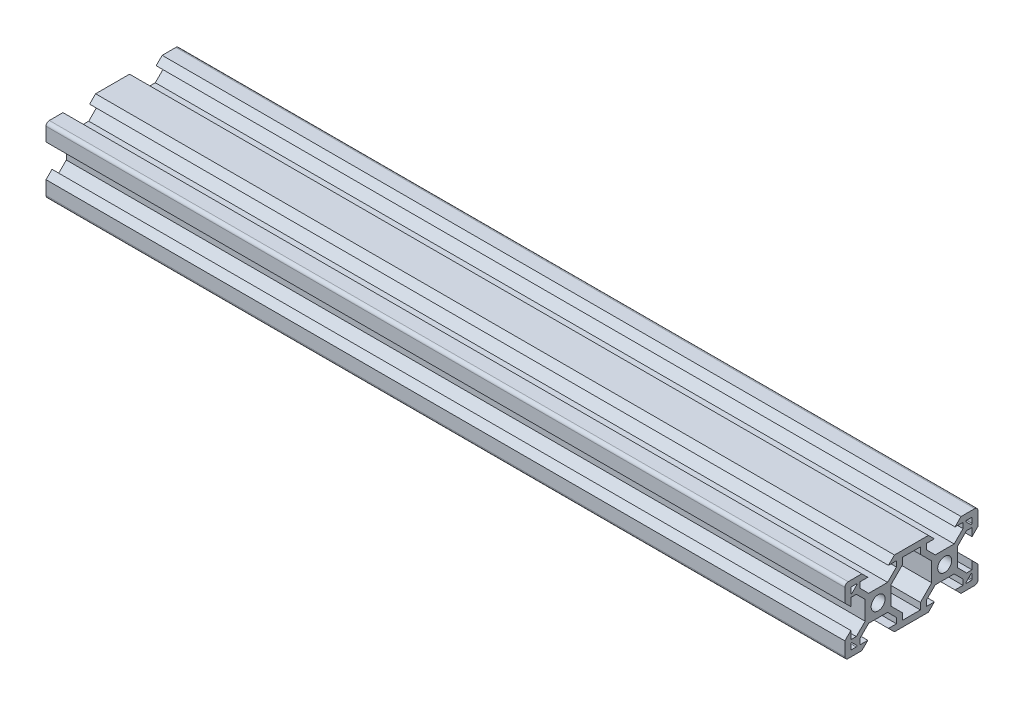
from build123d import *

# Parameters (mm, degrees)
SKETCH5_R           = 2.1
BOSS_EXTRUDE1_DEPTH = 120


with BuildPart() as part:
    # Sketch5 → Boss-Extrude1 (new body, symmetric)
    with BuildSketch(Plane(origin=(0, 0, 0), x_dir=(0, 0, -1), z_dir=(1, 0, 0))):
        with BuildLine():
            Line((-19.998019485, 4.9), (-18.198019485, 3.1))
            Line((-18.198019485, 3.1), (-18.198019485, 5.499339828))
            Line((-18.198019485, 5.499339828), (-16.558019485, 5.499339828))
            Line((-16.558019485, 5.499339828), (-13.9, 2.841320344))
            Line((-13.9, 2.841320344), (-13.9, -2.838679656))
            Line((-13.9, -2.838679656), (-16.558019485, -5.496699141))
            Line((-16.558019485, -5.496699141), (-18.198019485, -5.496699141))
            Line((-18.198019485, -5.496699141), (-18.198019485, -3.1))
            Line((-18.198019485, -3.1), (-19.998019485, -4.9))
            Line((-19.998019485, -4.9), (-19.998019485, -9))
            ThreePointArc((-19.998019485, -9), (-19.705126266, -9.707106781), (-18.998019485, -10))
            Line((-18.998019485, -10), (-14.9, -10))
            Line((-14.9, -10), (-13.1, -8.2))
            Line((-13.1, -8.2), (-15.5, -8.2))
            Line((-15.5, -8.2), (-15.5, -6.56))
            Line((-15.5, -6.56), (-12.84, -3.9))
            Line((-12.84, -3.9), (-7.16, -3.9))
            Line((-7.16, -3.9), (-4.5, -6.56))
            Line((-4.5, -6.56), (-4.5, -8.2))
            Line((-4.5, -8.2), (-6.9, -8.2))
            Line((-6.9, -8.2), (-5.1, -10))
            Line((-5.1, -10), (5.1, -10))
            Line((5.1, -10), (6.9, -8.2))
            Line((6.9, -8.2), (4.496038969, -8.2))
            Line((4.496038969, -8.2), (4.496038969, -6.56))
            Line((4.496038969, -6.56), (7.156038969, -3.9))
            Line((7.156038969, -3.9), (12.836038969, -3.9))
            Line((12.836038969, -3.9), (15.496038969, -6.56))
            Line((15.496038969, -6.56), (15.496038969, -8.2))
            Line((15.496038969, -8.2), (13.1, -8.2))
            Line((13.1, -8.2), (14.9, -10))
            Line((14.9, -10), (19.001980515, -10))
            ThreePointArc((19.001980515, -10), (19.709087297, -9.707106781), (20.001980515, -9))
            Line((20.001980515, -9), (20.001980515, -4.9))
            Line((20.001980515, -4.9), (18.201980515, -3.1))
            Line((18.201980515, -3.1), (18.201980515, -5.504621202))
            Line((18.201980515, -5.504621202), (16.561980515, -5.504621202))
            Line((16.561980515, -5.504621202), (13.9, -2.842640687))
            Line((13.9, -2.842640687), (13.9, 2.837359313))
            Line((13.9, 2.837359313), (16.561980515, 5.499339828))
            Line((16.561980515, 5.499339828), (18.201980515, 5.499339828))
            Line((18.201980515, 5.499339828), (18.201980515, 3.1))
            Line((18.201980515, 3.1), (20.001980515, 4.9))
            Line((20.001980515, 4.9), (20.001980515, 9))
            ThreePointArc((20.001980515, 9), (19.709087297, 9.707106781), (19.001980515, 10))
            Line((19.001980515, 10), (14.9, 10))
            Line((14.9, 10), (13.1, 8.2))
            Line((13.1, 8.2), (15.501320344, 8.2))
            Line((15.501320344, 8.2), (15.501320344, 6.56))
            Line((15.501320344, 6.56), (12.841320344, 3.9))
            Line((12.841320344, 3.9), (7.161320344, 3.9))
            Line((7.161320344, 3.9), (4.501320344, 6.56))
            Line((4.501320344, 6.56), (4.501320344, 8.2))
            Line((4.501320344, 8.2), (6.9, 8.2))
            Line((6.9, 8.2), (5.1, 10))
            Line((5.1, 10), (-5.1, 10))
            Line((-5.1, 10), (-6.9, 8.2))
            Line((-6.9, 8.2), (-4.501320344, 8.2))
            Line((-4.501320344, 8.2), (-4.501320344, 6.56))
            Line((-4.501320344, 6.56), (-7.161320344, 3.9))
            Line((-7.161320344, 3.9), (-12.841320344, 3.9))
            Line((-12.841320344, 3.9), (-15.501320344, 6.56))
            Line((-15.501320344, 6.56), (-15.501320344, 8.2))
            Line((-15.501320344, 8.2), (-13.1, 8.2))
            Line((-13.1, 8.2), (-14.9, 10))
            Line((-14.9, 10), (-18.998019485, 10))
            ThreePointArc((-18.998019485, 10), (-19.705126266, 9.707106781), (-19.998019485, 9))
            Line((-19.998019485, 9), (-19.998019485, 4.9))
        make_face()
        with Locations((-10, 0)):
            Circle(SKETCH5_R, mode=Mode.SUBTRACT)
        with Locations((10, 0)):
            Circle(SKETCH5_R, mode=Mode.SUBTRACT)
        Polygon((6.1, -2.84), (6.1, 2.84), (2.7, 6.24), (2.7, 8.2), (-2.7, 8.2), (-2.7, 6.24), (-6.1, 2.84), (-6.1, -2.84), (-2.7, -6.24), (-2.7, -8.2), (2.7, -8.2), (2.7, -6.24), align=None, mode=Mode.SUBTRACT)
        with BuildLine():
            Line((16.571320344, 8.2), (18.001980515, 8.2))
            ThreePointArc((18.001980515, 8.2), (18.143401872, 8.141421356), (18.201980515, 8))
            Line((18.201980515, 8), (18.201980515, 6.569339828))
            ThreePointArc((18.201980515, 6.569339828), (18.078517202, 6.384563922), (17.860559159, 6.427918472))
            Line((17.860559159, 6.427918472), (16.429898987, 7.858578644))
            ThreePointArc((16.429898987, 7.858578644), (16.386544437, 8.076536686), (16.571320344, 8.2))
        make_face(mode=Mode.SUBTRACT)
        with BuildLine():
            Line((16.571320344, -8.2), (18.001980515, -8.2))
            ThreePointArc((18.001980515, -8.2), (18.143401872, -8.141421356), (18.201980515, -8))
            Line((18.201980515, -8), (18.201980515, -6.569339828))
            ThreePointArc((18.201980515, -6.569339828), (18.078517202, -6.384563922), (17.860559159, -6.427918472))
            Line((17.860559159, -6.427918472), (16.429898987, -7.858578644))
            ThreePointArc((16.429898987, -7.858578644), (16.386544437, -8.076536686), (16.571320344, -8.2))
        make_face(mode=Mode.SUBTRACT)
        with BuildLine():
            Line((-17.860559159, 6.427918472), (-16.429898987, 7.858578644))
            ThreePointArc((-16.429898987, 7.858578644), (-16.386544437, 8.076536686), (-16.571320344, 8.2))
            Line((-16.571320344, 8.2), (-18.001980515, 8.2))
            ThreePointArc((-18.001980515, 8.2), (-18.143401872, 8.141421356), (-18.201980515, 8))
            Line((-18.201980515, 8), (-18.201980515, 6.569339828))
            ThreePointArc((-18.201980515, 6.569339828), (-18.078517202, 6.384563922), (-17.860559159, 6.427918472))
        make_face(mode=Mode.SUBTRACT)
        with BuildLine():
            Line((-16.571320344, -8.2), (-18.001980515, -8.2))
            ThreePointArc((-18.001980515, -8.2), (-18.143401872, -8.141421356), (-18.201980515, -8))
            Line((-18.201980515, -8), (-18.201980515, -6.569339828))
            ThreePointArc((-18.201980515, -6.569339828), (-18.078517202, -6.384563922), (-17.860559159, -6.427918472))
            Line((-17.860559159, -6.427918472), (-16.429898987, -7.858578644))
            ThreePointArc((-16.429898987, -7.858578644), (-16.386544437, -8.076536686), (-16.571320344, -8.2))
        make_face(mode=Mode.SUBTRACT)
    extrude(amount=BOSS_EXTRUDE1_DEPTH, both=True)


solid = part.part
